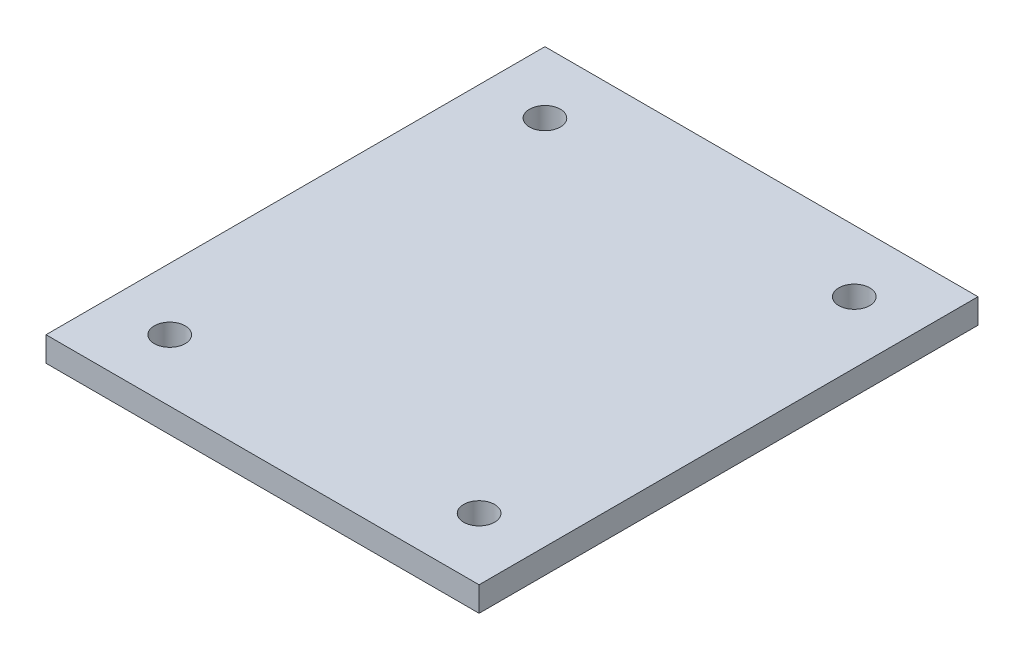
from build123d import *

# Parameters (mm, degrees)
SKETCH1_W           = 70
SKETCH1_H           = 80.64
BOSS_EXTRUDE1_DEPTH = 4
SKETCH2_R           = 2.5
CUT_EXTRUDE1_DEPTH  = 5


with BuildPart() as part:
    # Sketch1 → Boss-Extrude1 (new body)
    with BuildSketch(Plane(origin=(0, 0, 0), x_dir=(1, 0, 0), z_dir=(0, 1, 0))):
        with Locations((35, 40.32)):
            Rectangle(SKETCH1_W, SKETCH1_H)
    extrude(amount=BOSS_EXTRUDE1_DEPTH)

    # Sketch2 → Cut-Extrude1 (cut, through all)
    with BuildSketch(Plane(origin=(0, 4, 0), x_dir=(1, 0, 0), z_dir=(0, 1, 0))):
        with Locations((10, 70.64)):
            Circle(SKETCH2_R)
        with Locations((60, 70.64)):
            Circle(SKETCH2_R)
        with Locations((60, 10)):
            Circle(SKETCH2_R)
        with Locations((10, 10)):
            Circle(SKETCH2_R)
    extrude(amount=-CUT_EXTRUDE1_DEPTH, mode=Mode.SUBTRACT)


solid = part.part
